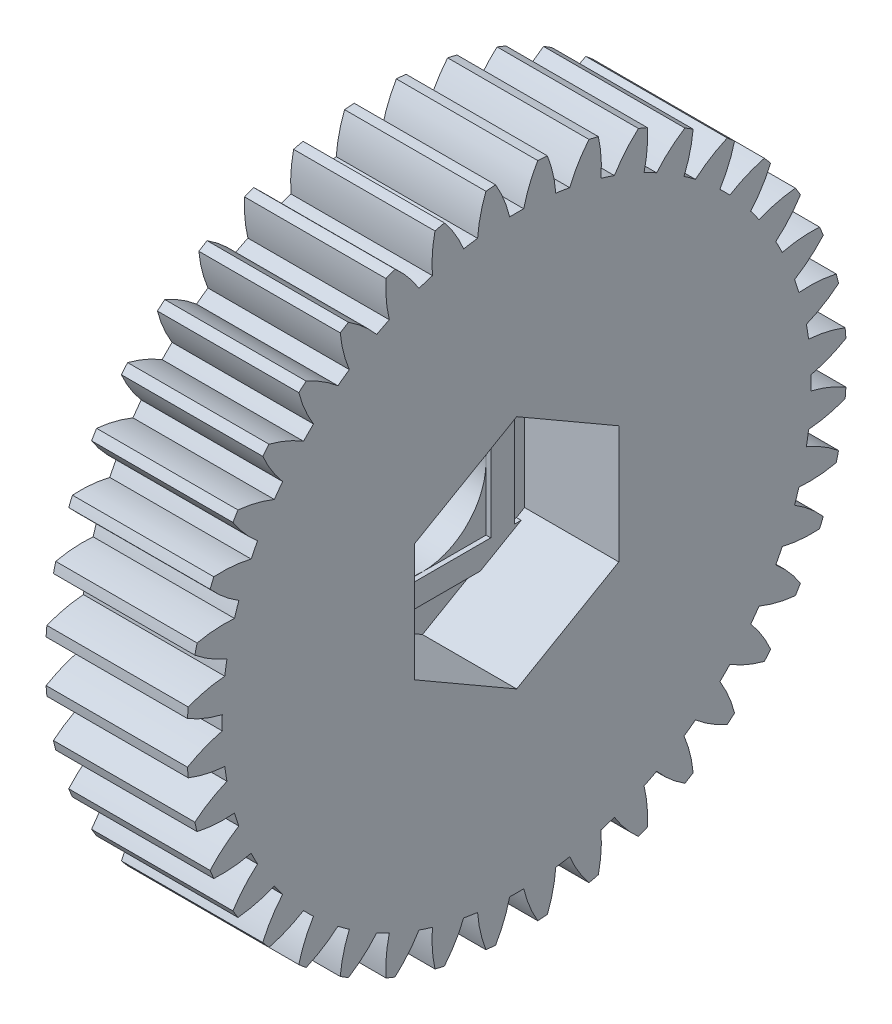
from build123d import *

# Parameters (mm, degrees)
BASPROSKE_W         = 9
BASPROSKE_H         = 21
TOOTHCUT_DEPTH      = 32.032241298
TEETHCUTS_COUNT     = 40
TEETHCUTS_ANGLE     = 351
BORSKE_R            = 2
BORE_DEPTH          = 50.0000508
CUT_EXTRUDE1_DEPTH  = 6
SKETCH1_7_R         = 4.05
CUT_EXTRUDE2_DEPTH  = 31.974304622
SKETCH2_R           = 6
SKETCH2_R_2         = 4
BOSS_EXTRUDE1_DEPTH = 1.8
SKETCH3_W           = 8.1
SKETCH3_H           = 8.1
BOSS_EXTRUDE2_DEPTH = 0.3


with BuildPart() as part:
    # BasProSke → Base-Revolve (revolve)
    with BuildSketch(Plane(origin=(0, 0, 0), x_dir=(1, 0, 0), z_dir=(0, 1, 0))):
        with Locations((4.5, 10.5)):
            Rectangle(BASPROSKE_W, BASPROSKE_H)
    revolve(axis=Axis((-10, 0, 0), (1, 0, 0)))

    # TooCutSke → ToothCut (cut, through all)
    with BuildSketch(Plane(origin=(0, 0, 0), x_dir=(0, 0, -1), z_dir=(1, 0, 0))):
        with BuildLine():
            ThreePointArc((0.448673268, 18.74363074), (0, 18.749), (-0.448673268, 18.74363074))
            ThreePointArc((-0.448673268, 18.74363074), (-0.816786816, 19.89705013), (-1.354745081, 20.981708961))
            ThreePointArc((-1.354745081, 20.981708961), (0, 21.0254), (1.354745081, 20.981708961))
            ThreePointArc((1.354745081, 20.981708961), (0.816786816, 19.89705013), (0.448673268, 18.74363074))
        make_face()
    toothcut = extrude(amount=TOOTHCUT_DEPTH, mode=Mode.SUBTRACT)

    # TeethCuts: ToothCut ×40 about axis
    teethcuts_axis = Axis((-10, 0, 0), (1, 0, 0))
    for i in range(1, TEETHCUTS_COUNT):
        add(toothcut.rotate(teethcuts_axis, i * TEETHCUTS_ANGLE / (TEETHCUTS_COUNT - 1)), mode=Mode.SUBTRACT)

    # BorSke → Bore (cut, symmetric)
    with BuildSketch(Plane(origin=(0, 0, 0), x_dir=(0, 0, -1), z_dir=(1, 0, 0))):
        Circle(BORSKE_R)
    extrude(amount=BORE_DEPTH, both=True, mode=Mode.SUBTRACT)

    # Sketch1 → Cut-Extrude1 (cut)
    with BuildSketch(Plane(origin=(9, 0, 0), x_dir=(0, 0, -1), z_dir=(1, 0, 0))):
        Polygon((0, 7.505553499), (-6.5, 3.75277675), (-6.5, -3.75277675), (0, -7.505553499), (6.5, -3.75277675), (6.5, 3.75277675), align=None)
    extrude(amount=-CUT_EXTRUDE1_DEPTH, mode=Mode.SUBTRACT)

    # Sketch1_7 → Cut-Extrude2 (cut, through all)
    with BuildSketch(Plane(origin=(9, 0, 0), x_dir=(0, 0, -1), z_dir=(1, 0, 0))):
        Circle(SKETCH1_7_R)
    extrude(amount=-CUT_EXTRUDE2_DEPTH, mode=Mode.SUBTRACT)

    # Sketch2 → Boss-Extrude1 (add)
    with BuildSketch(Plane.ZY):
        Circle(SKETCH2_R)
        Circle(SKETCH2_R_2, mode=Mode.SUBTRACT)
    extrude(amount=BOSS_EXTRUDE1_DEPTH)

    # Sketch3 → Boss-Extrude2 (add)
    with BuildSketch(Plane(origin=(3, 0, 0), x_dir=(0, 0, -1), z_dir=(1, 0, 0))):
        Polygon((5.55, -4.05), (5.55, 4.05), (5.985194229, 4.05), (3.387118018, 5.55), (-3.387118018, 5.55), (-5.985194229, 4.05), (-5.55, 4.05), (-5.55, -4.05), (-5.985194229, -4.05), (-3.387118018, -5.55), (3.387118018, -5.55), (5.985194229, -4.05), align=None)
        Rectangle(SKETCH3_W, SKETCH3_H, mode=Mode.SUBTRACT)
    extrude(amount=BOSS_EXTRUDE2_DEPTH)


solid = part.part
